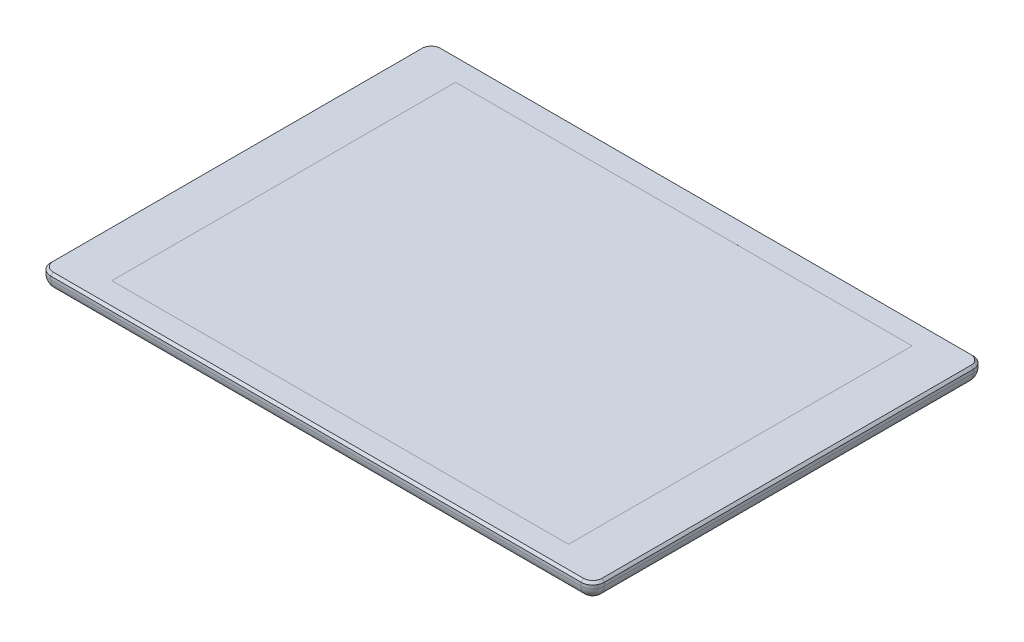
from build123d import *

# Parameters (mm, degrees)
BOSS_EXTRUDE1_DEPTH = 7.5
FILLET1_R           = 5
CHAMFER1_SIZE       = 1
SKETCH2_W           = 198
SKETCH2_H           = 149
CUT_EXTRUDE1_DEPTH  = 0.0001


with BuildPart() as part:
    # Sketch1 → Boss-Extrude1 (new body)
    with BuildSketch(Plane(origin=(0, 0, 0), x_dir=(1, 0, 0), z_dir=(0, 1, 0))):
        with BuildLine():
            Line((5, 0), (235, 0))
            ThreePointArc((235, 0), (238.535533906, 1.464466094), (240, 5))
            Line((240, 5), (240, 165))
            ThreePointArc((240, 165), (238.535533906, 168.535533906), (235, 170))
            Line((235, 170), (5, 170))
            ThreePointArc((5, 170), (1.464466094, 168.535533906), (0, 165))
            Line((0, 165), (0, 5))
            ThreePointArc((0, 5), (1.464466094, 1.464466094), (5, 0))
        make_face()
    extrude(amount=BOSS_EXTRUDE1_DEPTH)

    # Fillet1
    fillet1_edges = [part.edges().sort_by_distance(p)[0] for p in [
        (120, 0, 0),
        (1.464466094, 0, -1.464466094),
        (0, 0, -85),
        (1.464466094, 0, -168.535533906),
        (120, 0, -170),
        (238.535533906, 0, -168.535533906),
        (240, 0, -85),
        (238.535533906, 0, -1.464466094),
    ]]
    fillet(fillet1_edges, radius=FILLET1_R)

    # Chamfer1
    chamfer1_edges = [part.edges().sort_by_distance(p)[0] for p in [
        (238.535533906, 7.5, -1.464466094),
        (240, 7.5, -85),
        (238.535533906, 7.5, -168.535533906),
        (120, 7.5, -170),
        (1.464466094, 7.5, -168.535533906),
        (0, 7.5, -85),
        (1.464466094, 7.5, -1.464466094),
        (120, 7.5, 0),
    ]]
    chamfer(chamfer1_edges, length=CHAMFER1_SIZE)

    # Sketch2 → Cut-Extrude1 (cut)
    with BuildSketch(Plane(origin=(0, 7.5, 0), x_dir=(1, 0, 0), z_dir=(0, 1, 0))):
        with Locations((120, 85)):
            Rectangle(SKETCH2_W, SKETCH2_H)
    extrude(amount=-CUT_EXTRUDE1_DEPTH, mode=Mode.SUBTRACT)


solid = part.part
